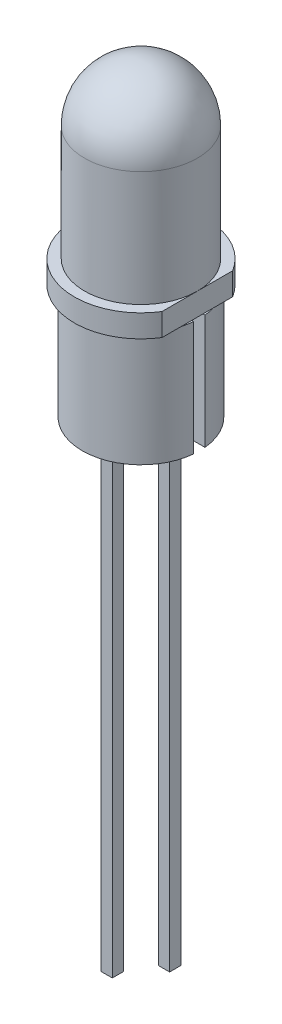
from build123d import *

# Parameters (mm, degrees)
EXTRUDE1_DEPTH     = 1
SKETCH3_W          = 0.5
SKETCH3_H          = 0.5
EXTRUDE2_DEPTH     = 27
SKETCH3_3_W        = 0.5
SKETCH3_3_H        = 0.5
EXTRUDE3_DEPTH     = 25.5
EXTRUDE5_DEPTH     = 5.08
CUT_EXTRUDE1_DEPTH = 0.01


with BuildPart() as part:
    # Sketch1 → Revolve1 (revolve)
    with BuildSketch(Plane.XY, mode=Mode.PRIVATE) as revolve1_sk:
        with BuildLine():
            ThreePointArc((0, 7.6), (1.767766953, 6.867766953), (2.5, 5.1))
            Line((2.5, 5.1), (2.5, 0))
            Line((2.5, 0), (0, 0))
            Line((0, 0), (0, 7.6))
        make_face()
    revolve(revolve1_sk.sketch.rotate(Axis((0, 0, 0), (0, 1, 0)), 180), axis=Axis((0, 0, 0), (0, 1, 0)))  # turned: the seam where the file's is

    # Sketch2 → Extrude1 (add)
    with BuildSketch(Plane.XZ.offset(1)):
        with BuildLine():
            ThreePointArc((2.5, 1.566045976), (-2.95, 0), (2.5, -1.566045976))
            Line((2.5, -1.566045976), (2.5, 1.566045976))
        make_face()
    extrude(amount=-EXTRUDE1_DEPTH)

    # Sketch3 → Extrude2 (add)
    with BuildSketch(Plane.XZ.offset(1)):
        with Locations((-1.27, 0)):
            Rectangle(SKETCH3_W, SKETCH3_H)
    extrude(amount=EXTRUDE2_DEPTH)

    # Sketch3_3 → Extrude3 (add)
    with BuildSketch(Plane.XZ.offset(1)):
        with Locations((1.27, 0)):
            Rectangle(SKETCH3_3_W, SKETCH3_3_H)
    extrude(amount=EXTRUDE3_DEPTH)

    # Sketch3_4 → Extrude5 (add)
    with BuildSketch(Plane.XZ.offset(1)):
        with BuildLine():
            Line((-2.587952859, 0.25), (-1.5325, 0.25))
            ThreePointArc((-1.5325, 0.25), (-0.9075, 0), (-1.5325, -0.25))
            Line((-1.5325, -0.25), (-2.587952859, -0.25))
            ThreePointArc((-2.587952859, -0.25), (0, -2.6), (2.587952859, -0.25))
            Line((2.587952859, -0.25), (1.5325, -0.25))
            ThreePointArc((1.5325, -0.25), (0.9075, 0), (1.5325, 0.25))
            Line((1.5325, 0.25), (2.587952859, 0.25))
            ThreePointArc((2.587952859, 0.25), (0, 2.6), (-2.587952859, 0.25))
        make_face()
    extrude(amount=EXTRUDE5_DEPTH)

    # Sketch4 → Cut-Extrude1 (cut)
    with BuildSketch(Plane.XZ.offset(6.08)):
        Polygon((-0.655355375, -1.39060173), (-0.685517559, -1.463426097), (-0.711012021, -1.461052679), (-0.721613287, -1.409114388), (-0.741332432, -1.458244135), (-0.767163129, -1.455850939), (-0.783243034, -1.37875442), (-0.758005692, -1.38108828), (-0.749975629, -1.433936382), (-0.729168667, -1.383778154), (-0.707887021, -1.385736224), (-0.697443983, -1.438821667), (-0.68003892, -1.388327205), align=None)
        Polygon((-0.521758682, -1.403069635), (-0.551920866, -1.475894002), (-0.577415328, -1.473520585), (-0.588016594, -1.421582294), (-0.607735739, -1.47071204), (-0.633566435, -1.468318844), (-0.649646341, -1.391222325), (-0.624408999, -1.393556186), (-0.616378935, -1.446404287), (-0.595571973, -1.396246059), (-0.574290328, -1.398204129), (-0.56384729, -1.451289572), (-0.546442227, -1.40079511), align=None)
        Polygon((-0.388161989, -1.415537541), (-0.418324173, -1.488361908), (-0.443818635, -1.48598849), (-0.454419901, -1.434050199), (-0.474139046, -1.483179946), (-0.499969742, -1.48078675), (-0.516049647, -1.403690231), (-0.490812306, -1.406024091), (-0.482782242, -1.458872193), (-0.46197528, -1.408713965), (-0.440693635, -1.410672034), (-0.430250597, -1.463757477), (-0.412845534, -1.413263015), align=None)
        Polygon((-0.355217986, -1.494283136), (-0.380178429, -1.491969054), (-0.377745676, -1.465742788), (-0.352785233, -1.46805687), align=None)
        with BuildLine():
            add(Edge.make_bspline(
                [(-0.248113536, -1.472723232), (-0.248253922, -1.473915629), (-0.248530252, -1.476262694), (-0.249473853, -1.479641652), (-0.250729627, -1.482831413), (-0.252387391, -1.485803259), (-0.254429344, -1.4885535), (-0.256837161, -1.491099172), (-0.259635793, -1.493419728), (-0.262773235, -1.495519624), (-0.266205588, -1.497388194), (-0.269935055, -1.498900162), (-0.273902913, -1.500135313), (-0.278129153, -1.501027047), (-0.282595924, -1.501653514), (-0.287317312, -1.501902071), (-0.292291902, -1.501898945), (-0.295681806, -1.5016359), (-0.297421289, -1.501500922)],
                knots=[0, 0, 0, 0, 0.90058851, 1.772681517, 2.626015198, 3.4705971, 4.32036009, 5.192579617, 6.09606324, 7.045094186, 8.024414859, 9.025845661, 10.062717298, 11.141783603, 12.26648138, 13.447065521, 14.689996688, 16, 16, 16, 16], degree=3))
            add(Edge.make_bspline(
                [(-0.297421289, -1.501500922), (-0.299408593, -1.501291869), (-0.303257868, -1.500886946), (-0.308800989, -1.499944314), (-0.313939341, -1.498819187), (-0.318688263, -1.497416894), (-0.323132496, -1.495802648), (-0.327380334, -1.494085584), (-0.331477438, -1.492249874), (-0.334109446, -1.490898096), (-0.335415751, -1.490227188)],
                knots=[0, 0, 0, 0, 1.201286002, 2.32681153, 3.378988205, 4.362447621, 5.301645787, 6.221100837, 7.117105525, 8, 8, 8, 8], degree=3))
            Line((-0.335415751, -1.490227188), (-0.33322034, -1.466394118))
            Line((-0.33322034, -1.466394118), (-0.330411796, -1.466651239))
            add(Edge.make_bspline(
                [(-0.330411796, -1.466651239), (-0.329166575, -1.467796655), (-0.326671467, -1.470091782), (-0.322547402, -1.473096042), (-0.318188353, -1.47580979), (-0.313584524, -1.478115397), (-0.308880084, -1.48003939), (-0.304179683, -1.481549193), (-0.299537996, -1.482653268), (-0.296437117, -1.483023451), (-0.294909422, -1.483205827)],
                knots=[0, 0, 0, 0, 1.017616757, 2.039048384, 3.065385926, 4.105318742, 5.134016281, 6.121643996, 7.074599551, 8, 8, 8, 8], degree=3))
            add(Edge.make_bspline(
                [(-0.294909422, -1.483205827), (-0.294487695, -1.483241941), (-0.293585992, -1.483319157), (-0.292134278, -1.483373746), (-0.290498946, -1.483382814), (-0.288731062, -1.483401798), (-0.286956546, -1.483315507), (-0.285283972, -1.483192549), (-0.283781583, -1.482962621), (-0.282849645, -1.482724809), (-0.282409422, -1.482612473)],
                knots=[0, 0, 0, 0, 0.808163916, 1.727951266, 2.772930738, 3.931137178, 5.10301526, 6.164173594, 7.132806016, 8, 8, 8, 8], degree=3))
            add(Edge.make_bspline(
                [(-0.282409422, -1.482612473), (-0.281918703, -1.482448763), (-0.280962984, -1.482129925), (-0.279617609, -1.481537584), (-0.278396185, -1.4808599), (-0.277289642, -1.48009404), (-0.276319294, -1.479155115), (-0.275599646, -1.477942168), (-0.275107425, -1.476500027), (-0.274967193, -1.475449948), (-0.2748936, -1.474898865)],
                knots=[0, 0, 0, 0, 1.070797189, 2.085469699, 3.038870334, 3.959349101, 4.866776555, 5.810352107, 6.850870467, 8, 8, 8, 8], degree=3))
            add(Edge.make_bspline(
                [(-0.2748936, -1.474898865), (-0.274871056, -1.474361982), (-0.274826642, -1.473304246), (-0.275272712, -1.471754544), (-0.276004603, -1.470276952), (-0.277160522, -1.468931276), (-0.278612196, -1.46765572), (-0.280421798, -1.46652515), (-0.282533606, -1.465458035), (-0.284096157, -1.464905717), (-0.284921289, -1.464614055)],
                knots=[0, 0, 0, 0, 0.825752642, 1.626850376, 2.461116157, 3.359088001, 4.348717287, 5.440157492, 6.648229248, 8, 8, 8, 8], degree=3))
            add(Edge.make_bspline(
                [(-0.284921289, -1.464614055), (-0.286796238, -1.463994137), (-0.290642297, -1.462722507), (-0.296536902, -1.461054323), (-0.302402704, -1.459265762), (-0.306141452, -1.457701982), (-0.30796322, -1.456940005)],
                knots=[0, 0, 0, 0, 0.974993485, 1.999993149, 3.025463197, 4, 4, 4, 4], degree=3))
            add(Edge.make_bspline(
                [(-0.30796322, -1.456940005), (-0.308943214, -1.456500785), (-0.310851641, -1.455645455), (-0.313566505, -1.454246027), (-0.316040774, -1.452761585), (-0.318292733, -1.451216392), (-0.320318879, -1.449592995), (-0.322120139, -1.447895058), (-0.323701826, -1.446130545), (-0.3250332, -1.44427218), (-0.326169708, -1.442338136), (-0.327123206, -1.440321228), (-0.327872522, -1.438211568), (-0.328450718, -1.436022174), (-0.328845015, -1.433738863), (-0.329055645, -1.431364867), (-0.32910794, -1.428904178), (-0.328975807, -1.427245359), (-0.328908631, -1.42640203)],
                knots=[0, 0, 0, 0, 1.283065564, 2.498625262, 3.646979989, 4.728630173, 5.759609417, 6.745952661, 7.683425923, 8.586370769, 9.472667486, 10.360712945, 11.247779533, 12.14392913, 13.063456901, 14.012738052, 14.989693508, 16, 16, 16, 16], degree=3))
            add(Edge.make_bspline(
                [(-0.328908631, -1.42640203), (-0.328764477, -1.425269782), (-0.328482025, -1.423051277), (-0.32759699, -1.419842499), (-0.32631903, -1.41684554), (-0.324690584, -1.414020102), (-0.322647072, -1.411425051), (-0.320254722, -1.409011987), (-0.317480907, -1.406811894), (-0.314359888, -1.40482933), (-0.310961723, -1.403086519), (-0.307337403, -1.401608337), (-0.303506133, -1.400454947), (-0.299489466, -1.399553272), (-0.295272931, -1.398998708), (-0.290866881, -1.398692798), (-0.28626042, -1.398721411), (-0.283133661, -1.39895106), (-0.281539169, -1.399068169)],
                knots=[0, 0, 0, 0, 0.898352996, 1.760216372, 2.612020855, 3.459189028, 4.321506127, 5.206609067, 6.130498421, 7.104463332, 8.114927556, 9.135353876, 10.183556409, 11.263499099, 12.374845914, 13.530505901, 14.740680187, 16, 16, 16, 16], degree=3))
            add(Edge.make_bspline(
                [(-0.281539169, -1.399068169), (-0.279908488, -1.399242299), (-0.27665549, -1.399589666), (-0.271824799, -1.400414813), (-0.267045258, -1.401461102), (-0.262365573, -1.402744441), (-0.257873382, -1.404167144), (-0.253661922, -1.40569312), (-0.249775116, -1.407292903), (-0.247348787, -1.408508103), (-0.246175245, -1.409095859)],
                knots=[0, 0, 0, 0, 1.064569354, 2.123677063, 3.179952291, 4.240175319, 5.273112175, 6.23860218, 7.148064866, 8, 8, 8, 8], degree=3))
            Line((-0.246175245, -1.409095859), (-0.248291543, -1.43199934))
            Line((-0.248291543, -1.43199934), (-0.251020973, -1.43174222))
            add(Edge.make_bspline(
                [(-0.251020973, -1.43174222), (-0.251995829, -1.430861762), (-0.253992805, -1.42905816), (-0.257324932, -1.426617934), (-0.261021517, -1.424361356), (-0.264998344, -1.422262437), (-0.269207224, -1.420456191), (-0.273552202, -1.419021056), (-0.277978999, -1.417968969), (-0.280987213, -1.417617692), (-0.282488536, -1.417442378)],
                knots=[0, 0, 0, 0, 0.896004807, 1.835450662, 2.81312924, 3.849541625, 4.901693663, 5.934613881, 6.969218071, 8, 8, 8, 8], degree=3))
            add(Edge.make_bspline(
                [(-0.282488536, -1.417442378), (-0.283556031, -1.41736002), (-0.285689074, -1.417195455), (-0.288890088, -1.417243675), (-0.292080537, -1.417532248), (-0.294137022, -1.418078648), (-0.295166543, -1.418352188)],
                knots=[0, 0, 0, 0, 1.004193435, 2.006555513, 3.00203922, 4, 4, 4, 4], degree=3))
            add(Edge.make_bspline(
                [(-0.295166543, -1.418352188), (-0.295606035, -1.418485758), (-0.296486336, -1.418753297), (-0.297719584, -1.419357624), (-0.298890862, -1.420071954), (-0.299939018, -1.420932432), (-0.300862918, -1.42189142), (-0.301570012, -1.422973779), (-0.302040535, -1.424167281), (-0.302164575, -1.425007113), (-0.30222746, -1.425432884)],
                knots=[0, 0, 0, 0, 1.035909408, 2.074917629, 3.091381753, 4.128574551, 5.129321193, 6.087511365, 7.030423625, 8, 8, 8, 8], degree=3))
            add(Edge.make_bspline(
                [(-0.30222746, -1.425432884), (-0.30225038, -1.426061006), (-0.302294131, -1.427260013), (-0.301882482, -1.429000848), (-0.301053004, -1.430536284), (-0.300016884, -1.431627475), (-0.298969504, -1.43238867), (-0.298024393, -1.4330126), (-0.29687876, -1.433591989), (-0.295582439, -1.434205533), (-0.294115905, -1.434815726), (-0.292483004, -1.435425001), (-0.290695609, -1.436064426), (-0.28943257, -1.436448346), (-0.288778093, -1.436647283)],
                knots=[0, 0, 0, 0, 1.176031048, 2.244899041, 3.313838711, 4.417270275, 5.036199696, 5.743514448, 6.540853141, 7.443472104, 8.4366176, 9.521775806, 10.715844498, 12, 12, 12, 12], degree=3))
            add(Edge.make_bspline(
                [(-0.288778093, -1.436647283), (-0.287024719, -1.437188984), (-0.283595768, -1.43824835), (-0.278436226, -1.439821907), (-0.273200308, -1.441592092), (-0.269710622, -1.443022235), (-0.267892017, -1.443767536)],
                knots=[0, 0, 0, 0, 0.997445159, 1.95063395, 2.931999127, 4, 4, 4, 4], degree=3))
            add(Edge.make_bspline(
                [(-0.267892017, -1.443767536), (-0.266996982, -1.444165802), (-0.265250305, -1.444943024), (-0.262779227, -1.44625508), (-0.260497186, -1.447624665), (-0.258391793, -1.449033604), (-0.256502434, -1.450552149), (-0.254800145, -1.452128806), (-0.253287942, -1.453773186), (-0.251973219, -1.455488674), (-0.250824963, -1.457277317), (-0.249899101, -1.45918817), (-0.249152808, -1.461198041), (-0.248539484, -1.463294498), (-0.248184389, -1.46551391), (-0.247963418, -1.467825748), (-0.247915361, -1.4702476), (-0.248046559, -1.471886548), (-0.248113536, -1.472723232)],
                knots=[0, 0, 0, 0, 1.235962929, 2.412004647, 3.527791942, 4.593898695, 5.606083112, 6.58329943, 7.519603077, 8.421527213, 9.307852042, 10.197139612, 11.094948425, 12.011489434, 12.948421262, 13.926133287, 14.941288146, 16, 16, 16, 16], degree=3))
        make_face()
        with BuildLine():
            Line((-0.160164983, -1.512456531), (-0.184195838, -1.510241341))
            Line((-0.184195838, -1.510241341), (-0.183424477, -1.501954158))
            add(Edge.make_bspline(
                [(-0.183424477, -1.501954158), (-0.184578993, -1.502656368), (-0.186809843, -1.504013234), (-0.190127683, -1.505812672), (-0.19327933, -1.507327346), (-0.196314753, -1.508577078), (-0.199396803, -1.509520262), (-0.202671593, -1.510002425), (-0.206170787, -1.510197349), (-0.208569943, -1.510030719), (-0.20980897, -1.509944664)],
                knots=[0, 0, 0, 0, 1.151271807, 2.224579471, 3.214562626, 4.129415358, 5.019918913, 5.952705277, 6.942688433, 8, 8, 8, 8], degree=3))
            add(Edge.make_bspline(
                [(-0.20980897, -1.509944664), (-0.210813447, -1.509828682), (-0.212768834, -1.509602904), (-0.21559046, -1.5090085), (-0.218206943, -1.50820224), (-0.220623003, -1.507183849), (-0.222853049, -1.505980581), (-0.224886297, -1.504554967), (-0.22669302, -1.502888377), (-0.22832631, -1.501050323), (-0.229738359, -1.499000357), (-0.230911904, -1.496747911), (-0.231831983, -1.494299802), (-0.232553108, -1.491673037), (-0.233013962, -1.488848714), (-0.233270067, -1.485833963), (-0.233291224, -1.482626036), (-0.233117966, -1.480434368), (-0.233028907, -1.479307797)],
                knots=[0, 0, 0, 0, 1.105679804, 2.15239592, 3.149250959, 4.096256038, 5.016039341, 5.916477075, 6.804759926, 7.698966383, 8.601193048, 9.52055213, 10.470189916, 11.456949629, 12.495584415, 13.595817429, 14.764191139, 16, 16, 16, 16], degree=3))
            Line((-0.233028907, -1.479307797), (-0.228519414, -1.430514284))
            Line((-0.228519414, -1.430514284), (-0.20435011, -1.432769031))
            Line((-0.20435011, -1.432769031), (-0.207791565, -1.469952575))
            add(Edge.make_bspline(
                [(-0.207791565, -1.469952575), (-0.207875574, -1.470862006), (-0.208035545, -1.472593778), (-0.208188447, -1.475080629), (-0.208296251, -1.477328913), (-0.208321728, -1.479360933), (-0.208257476, -1.481206454), (-0.208040583, -1.482887626), (-0.207701347, -1.484426243), (-0.207334997, -1.48536368), (-0.207158654, -1.485814917)],
                knots=[0, 0, 0, 0, 1.367849549, 2.604711154, 3.73150806, 4.738774859, 5.648104615, 6.494452549, 7.275302687, 8, 8, 8, 8], degree=3))
            add(Edge.make_bspline(
                [(-0.207158654, -1.485814917), (-0.206969063, -1.486232052), (-0.206599495, -1.487045168), (-0.205790976, -1.488123345), (-0.20482863, -1.489054973), (-0.20365081, -1.489825537), (-0.202261679, -1.490468148), (-0.200602754, -1.490935367), (-0.19869457, -1.491341432), (-0.197324193, -1.491491053), (-0.196596945, -1.491570455)],
                knots=[0, 0, 0, 0, 0.862146275, 1.680569997, 2.525040964, 3.377080088, 4.323068773, 5.401195608, 6.620835126, 8, 8, 8, 8], degree=3))
            add(Edge.make_bspline(
                [(-0.196596945, -1.491570455), (-0.196069756, -1.491606169), (-0.194982779, -1.491679806), (-0.193301686, -1.491609608), (-0.191526916, -1.491400102), (-0.189013526, -1.490985952), (-0.185814683, -1.490104715), (-0.183397248, -1.488975316), (-0.182178433, -1.488405898)],
                knots=[0, 0, 0, 0, 0.636343377, 1.312035106, 2.023532984, 2.788877082, 4.381024352, 6, 6, 6, 6], degree=3))
            Line((-0.182178433, -1.488405898), (-0.177253591, -1.435280898))
            Line((-0.177253591, -1.435280898), (-0.153222736, -1.437496088))
            Line((-0.153222736, -1.437496088), (-0.160164983, -1.512456531))
        make_face()
        with BuildLine():
            Line((-0.062505196, -1.521572741), (-0.0866745, -1.519337773))
            Line((-0.0866745, -1.519337773), (-0.083233044, -1.482154229))
            add(Edge.make_bspline(
                [(-0.083233044, -1.482154229), (-0.083120754, -1.480645307), (-0.082895909, -1.477623887), (-0.082817229, -1.473879451), (-0.082914609, -1.471028842), (-0.083069528, -1.469173946), (-0.083375097, -1.467605831), (-0.083698137, -1.466691239), (-0.083846177, -1.466272108)],
                knots=[0, 0, 0, 0, 1.702009942, 3.408054733, 4.209582085, 4.909917854, 5.500447295, 6, 6, 6, 6], degree=3))
            add(Edge.make_bspline(
                [(-0.083846177, -1.466272108), (-0.084042538, -1.465854922), (-0.084429718, -1.465032327), (-0.08526265, -1.463950395), (-0.086262932, -1.463032258), (-0.087448278, -1.462264163), (-0.088840032, -1.461627323), (-0.090482416, -1.461121054), (-0.092390297, -1.460728829), (-0.093760071, -1.460577239), (-0.094487, -1.460496792)],
                knots=[0, 0, 0, 0, 0.864192863, 1.703986622, 2.54551408, 3.404364673, 4.34644313, 5.411937724, 6.626535882, 8, 8, 8, 8], degree=3))
            add(Edge.make_bspline(
                [(-0.094487, -1.460496792), (-0.095595804, -1.460447064), (-0.097858192, -1.4603456), (-0.100714428, -1.460796709), (-0.103052256, -1.461401308), (-0.104922302, -1.461989303), (-0.106859463, -1.462777028), (-0.108169277, -1.463373089), (-0.108846177, -1.463681127)],
                knots=[0, 0, 0, 0, 1.339357892, 2.732805435, 3.473325484, 4.259912674, 5.100739573, 6, 6, 6, 6], degree=3))
            Line((-0.108846177, -1.463681127), (-0.113771019, -1.516825906))
            Line((-0.113771019, -1.516825906), (-0.137801873, -1.514590938))
            Line((-0.137801873, -1.514590938), (-0.130859626, -1.439630495))
            Line((-0.130859626, -1.439630495), (-0.106828772, -1.441865463))
            Line((-0.106828772, -1.441865463), (-0.107580354, -1.450132868))
            add(Edge.make_bspline(
                [(-0.107580354, -1.450132868), (-0.106460188, -1.449435079), (-0.104278258, -1.448075881), (-0.100977579, -1.446295664), (-0.097760054, -1.444805586), (-0.094609608, -1.443563894), (-0.091414897, -1.442652186), (-0.088120084, -1.44209451), (-0.084688801, -1.441917117), (-0.08237541, -1.442066298), (-0.08119586, -1.442142362)],
                knots=[0, 0, 0, 0, 1.125391853, 2.192109419, 3.195913079, 4.148252987, 5.077419607, 6.024015203, 6.992486454, 8, 8, 8, 8], degree=3))
            add(Edge.make_bspline(
                [(-0.08119586, -1.442142362), (-0.080210957, -1.44225009), (-0.078293646, -1.442459804), (-0.075525409, -1.443059579), (-0.072950877, -1.443878762), (-0.070539009, -1.444853124), (-0.068325902, -1.446073096), (-0.066300573, -1.44749759), (-0.064471176, -1.449137608), (-0.062809825, -1.450957518), (-0.061396173, -1.453009462), (-0.060162037, -1.455236609), (-0.059234532, -1.457688782), (-0.058489349, -1.460319867), (-0.058004033, -1.463157538), (-0.057762574, -1.466194077), (-0.057706314, -1.46942779), (-0.057884231, -1.471639426), (-0.057975924, -1.472779229)],
                knots=[0, 0, 0, 0, 1.084667264, 2.111522093, 3.095855619, 4.041277855, 4.955890058, 5.857467287, 6.747401758, 7.642157225, 8.549643474, 9.470590754, 10.424031703, 11.413964681, 12.462254151, 13.571074575, 14.748214336, 16, 16, 16, 16], degree=3))
            Line((-0.057975924, -1.472779229), (-0.062505196, -1.521572741))
        make_face()
        Polygon((0.032266933, -1.530412053), (-0.03943006, -1.523766483), (-0.030213288, -1.424379616), (-0.004580377, -1.426772812), (-0.012017086, -1.506934996), (0.034046997, -1.511187369), align=None)
        Polygon((0.119428603, -1.538547732), (0.047533825, -1.531882384), (0.056750597, -1.432495517), (0.128645375, -1.439160865), (0.126865312, -1.458385548), (0.080484774, -1.454093618), (0.078882717, -1.471241561), (0.121920692, -1.475236814), (0.120140629, -1.494461498), (0.077102654, -1.490466245), (0.074828129, -1.515031118), (0.121208667, -1.519323048), align=None)
        with BuildLine():
            add(Edge.make_bspline(
                [(0.239316055, -1.499704273), (0.239193333, -1.500847086), (0.238950999, -1.503103745), (0.238317972, -1.506415515), (0.23754193, -1.509624942), (0.236539274, -1.512717949), (0.235382153, -1.515711806), (0.234007248, -1.518590636), (0.232446193, -1.521358648), (0.230704395, -1.524000612), (0.22883587, -1.526504528), (0.226849369, -1.528838701), (0.22479067, -1.531025465), (0.222636341, -1.533047092), (0.220380144, -1.534887639), (0.218034722, -1.536547972), (0.215624368, -1.538073617), (0.213934362, -1.538931436), (0.213089789, -1.539360128)],
                knots=[0, 0, 0, 0, 1.110090179, 2.192044121, 3.254966808, 4.298472341, 5.331150686, 6.354038145, 7.378015901, 8.399196196, 9.4094707, 10.394735033, 11.359019723, 12.309935786, 13.247097763, 14.169751205, 15.085341168, 16, 16, 16, 16], degree=3))
            add(Edge.make_bspline(
                [(0.213089789, -1.539360128), (0.211793815, -1.539943913), (0.209198802, -1.541112867), (0.205117352, -1.542450475), (0.200895563, -1.543444093), (0.196486056, -1.544068929), (0.191826954, -1.544395454), (0.18683636, -1.544457238), (0.18146364, -1.544307248), (0.177764366, -1.544005993), (0.175846909, -1.543849843)],
                knots=[0, 0, 0, 0, 0.897299183, 1.796721742, 2.707829584, 3.633617596, 4.606479989, 5.656017227, 6.785035701, 8, 8, 8, 8], degree=3))
            Line((0.175846909, -1.543849843), (0.140799441, -1.540586393))
            Line((0.140799441, -1.540586393), (0.150016213, -1.441199526))
            Line((0.150016213, -1.441199526), (0.186072384, -1.44454209))
            add(Edge.make_bspline(
                [(0.186072384, -1.44454209), (0.188026523, -1.444745793), (0.191801819, -1.445139336), (0.197219291, -1.446039811), (0.202207891, -1.44710329), (0.206756896, -1.448435542), (0.210901334, -1.449962588), (0.214680973, -1.451634539), (0.218090121, -1.453497827), (0.220130433, -1.454952281), (0.221119852, -1.455657596)],
                knots=[0, 0, 0, 0, 1.266615117, 2.447035418, 3.539391318, 4.553716614, 5.500588623, 6.385451449, 7.217048994, 8, 8, 8, 8], degree=3))
            add(Edge.make_bspline(
                [(0.221119852, -1.455657596), (0.221911963, -1.456274646), (0.223481268, -1.457497127), (0.225697193, -1.459490569), (0.227739338, -1.461623492), (0.229656517, -1.463869671), (0.231405702, -1.466240552), (0.233032474, -1.46872541), (0.234453706, -1.471359314), (0.235777859, -1.474086454), (0.236894548, -1.476939742), (0.237859501, -1.479885809), (0.238577249, -1.482952754), (0.239143134, -1.486106701), (0.239464847, -1.48937353), (0.239626591, -1.492726959), (0.239591135, -1.496188347), (0.239408843, -1.498518299), (0.239316055, -1.499704273)],
                knots=[0, 0, 0, 0, 0.965020829, 1.911869547, 2.862084641, 3.801779837, 4.748628555, 5.692609604, 6.654127927, 7.623591957, 8.605099481, 9.597189602, 10.600951773, 11.630375302, 12.675308291, 13.753889975, 14.856702544, 16, 16, 16, 16], degree=3))
        make_face()
        with BuildLine():
            add(Edge.make_bspline(
                [(0.212832669, -1.497034178), (0.212939465, -1.49545262), (0.213146001, -1.492394008), (0.212886564, -1.487925231), (0.21214949, -1.483769274), (0.211107618, -1.48054271), (0.210054719, -1.478130394), (0.209091946, -1.476436629), (0.20802813, -1.474795745), (0.206797061, -1.47326466), (0.205443613, -1.471801095), (0.203932626, -1.47044297), (0.202290797, -1.469148371), (0.201110116, -1.468373167), (0.200510675, -1.46797959)],
                knots=[0, 0, 0, 0, 1.705749779, 3.298789384, 4.806982686, 6.23946175, 6.938714637, 7.637967523, 8.335054416, 9.042477594, 9.750790903, 10.479588431, 11.228074284, 12, 12, 12, 12], degree=3))
            add(Edge.make_bspline(
                [(0.200510675, -1.46797959), (0.199883672, -1.46760603), (0.19864828, -1.466870002), (0.19670191, -1.465961952), (0.194735437, -1.465187551), (0.192644623, -1.464553153), (0.190281994, -1.463998987), (0.187462917, -1.463553966), (0.184122333, -1.463086008), (0.181709173, -1.462859629), (0.180415738, -1.462738292)],
                knots=[0, 0, 0, 0, 0.834463409, 1.644154416, 2.453704901, 3.250542573, 4.141482061, 5.22766562, 6.514049856, 8, 8, 8, 8], degree=3))
            Line((0.180415738, -1.462738292), (0.173928396, -1.462144938))
            Line((0.173928396, -1.462144938), (0.16815308, -1.52434826))
            Line((0.16815308, -1.52434826), (0.174640422, -1.524941615))
            add(Edge.make_bspline(
                [(0.174640422, -1.524941615), (0.175378473, -1.525011901), (0.176800687, -1.525147342), (0.178859793, -1.525272806), (0.180770764, -1.525399033), (0.182531241, -1.525487382), (0.184147163, -1.525492184), (0.185605096, -1.525512658), (0.186916917, -1.52543949), (0.188471459, -1.525346851), (0.190317812, -1.525095837), (0.192475067, -1.524575671), (0.194645739, -1.523970569), (0.196045787, -1.523393577), (0.196752764, -1.523102216)],
                knots=[0, 0, 0, 0, 1.188333874, 2.289901336, 3.306416931, 4.258483362, 5.114563353, 5.896601528, 6.594815215, 7.219763455, 8.393011118, 9.574842304, 10.775378443, 12, 12, 12, 12], degree=3))
            add(Edge.make_bspline(
                [(0.196752764, -1.523102216), (0.197934301, -1.522511428), (0.200243017, -1.521357033), (0.203299463, -1.519047003), (0.20594896, -1.516408026), (0.208131141, -1.513336208), (0.20990216, -1.509867893), (0.211268565, -1.505972432), (0.212316858, -1.501660297), (0.212656347, -1.498615543), (0.212832669, -1.497034178)],
                knots=[0, 0, 0, 0, 0.980860401, 1.916594154, 2.83557349, 3.752876285, 4.707000063, 5.723077786, 6.817426984, 8, 8, 8, 8], degree=3))
        make_face(mode=Mode.SUBTRACT)
        Polygon((0.278736133, -1.553446876), (0.25377569, -1.551132794), (0.256208443, -1.524906528), (0.281168886, -1.52722061), align=None)
        with BuildLine():
            add(Edge.make_bspline(
                [(0.340923653, -1.561258017), (0.339324981, -1.561082609), (0.336191108, -1.560738759), (0.33164068, -1.559854466), (0.327321112, -1.55873302), (0.323250487, -1.557335043), (0.319421653, -1.555664027), (0.315909487, -1.553648539), (0.312629603, -1.551411339), (0.310708603, -1.54963959), (0.309752766, -1.548758017)],
                knots=[0, 0, 0, 0, 1.127116313, 2.209483354, 3.246509375, 4.25363422, 5.224159382, 6.170115381, 7.089500056, 8, 8, 8, 8], degree=3))
            add(Edge.make_bspline(
                [(0.309752766, -1.548758017), (0.308877819, -1.54782241), (0.307128667, -1.545951992), (0.304936008, -1.542767138), (0.303087493, -1.539324433), (0.301587303, -1.535604188), (0.300522841, -1.531585661), (0.299901256, -1.527280521), (0.299696611, -1.522700367), (0.299911404, -1.519570763), (0.300021754, -1.517962922)],
                knots=[0, 0, 0, 0, 0.919337953, 1.83789453, 2.768295796, 3.722697843, 4.713165993, 5.747518477, 6.842782892, 8, 8, 8, 8], degree=3))
            add(Edge.make_bspline(
                [(0.300021754, -1.517962922), (0.30022019, -1.516276653), (0.300604697, -1.513009201), (0.301693971, -1.508337537), (0.303197985, -1.504070815), (0.305101481, -1.500196009), (0.307407516, -1.496727824), (0.309968424, -1.493568916), (0.312904497, -1.490812971), (0.315074466, -1.489267047), (0.316160994, -1.488492985)],
                knots=[0, 0, 0, 0, 1.169874094, 2.266842571, 3.299017176, 4.28282495, 5.234592693, 6.164557564, 7.080973184, 8, 8, 8, 8], degree=3))
            add(Edge.make_bspline(
                [(0.316160994, -1.488492985), (0.317269897, -1.487831633), (0.3194971, -1.486503325), (0.32307344, -1.484898522), (0.326866415, -1.483678824), (0.3308259, -1.482776281), (0.33491595, -1.48219863), (0.339071168, -1.481876407), (0.343282397, -1.481851364), (0.346093291, -1.482059153), (0.347509887, -1.482163871)],
                knots=[0, 0, 0, 0, 0.951091244, 1.910241889, 2.881417019, 3.883383244, 4.899762613, 5.923168624, 6.953347091, 8, 8, 8, 8], degree=3))
            add(Edge.make_bspline(
                [(0.347509887, -1.482163871), (0.348764869, -1.48229903), (0.351226288, -1.482564119), (0.354808868, -1.483234073), (0.358233251, -1.484045858), (0.361475678, -1.485116904), (0.364587995, -1.486305385), (0.367573858, -1.487606985), (0.370438713, -1.489034226), (0.372270872, -1.490086023), (0.373182355, -1.490609283)],
                knots=[0, 0, 0, 0, 1.111075928, 2.179172556, 3.207037671, 4.207604234, 5.183341174, 6.140033088, 7.074682433, 8, 8, 8, 8], degree=3))
            Line((0.373182355, -1.490609283), (0.371283621, -1.511099789))
            Line((0.371283621, -1.511099789), (0.367881722, -1.510783333))
            add(Edge.make_bspline(
                [(0.367881722, -1.510783333), (0.36740906, -1.510293432), (0.366386053, -1.509233113), (0.364691062, -1.507569808), (0.362660527, -1.505753926), (0.361072256, -1.50466019), (0.36022745, -1.504078428)],
                knots=[0, 0, 0, 0, 0.800878954, 1.733386287, 2.794381847, 4, 4, 4, 4], degree=3))
            add(Edge.make_bspline(
                [(0.36022745, -1.504078428), (0.359329898, -1.503515519), (0.357488794, -1.502360852), (0.354954313, -1.501251972), (0.35276522, -1.500483903), (0.350952102, -1.500015053), (0.348998019, -1.499632805), (0.347636635, -1.499486149), (0.346936311, -1.499410707)],
                knots=[0, 0, 0, 0, 1.3379742, 2.744522015, 3.485215376, 4.269639074, 5.109866742, 6, 6, 6, 6], degree=3))
            add(Edge.make_bspline(
                [(0.346936311, -1.499410707), (0.346158889, -1.499357872), (0.344637481, -1.499254474), (0.34240273, -1.499326394), (0.340294084, -1.499636819), (0.338291548, -1.500088619), (0.336432962, -1.500823505), (0.334667695, -1.50170632), (0.333041948, -1.502829143), (0.331535664, -1.504135724), (0.33017643, -1.505620884), (0.328952537, -1.507261845), (0.327898185, -1.50905761), (0.326969447, -1.510997942), (0.326233297, -1.51309891), (0.32561914, -1.515345703), (0.32513556, -1.517743565), (0.324955772, -1.519404844), (0.324863526, -1.520257226)],
                knots=[0, 0, 0, 0, 1.085847928, 2.124994152, 3.108863779, 4.053983921, 4.979052411, 5.887398504, 6.799965494, 7.725033985, 8.661626012, 9.600874533, 10.573346603, 11.559959446, 12.594829749, 13.671695504, 14.805376373, 16, 16, 16, 16], degree=3))
            add(Edge.make_bspline(
                [(0.324863526, -1.520257226), (0.324797994, -1.521133583), (0.324670491, -1.522838703), (0.324696335, -1.5253308), (0.32487549, -1.52767611), (0.325289773, -1.52986777), (0.32581939, -1.531932582), (0.326585346, -1.53383399), (0.327492741, -1.535603591), (0.32860863, -1.537201588), (0.329880246, -1.538663877), (0.331327644, -1.539945887), (0.332928329, -1.541064849), (0.334680825, -1.542016873), (0.33658553, -1.542804311), (0.338643961, -1.543439592), (0.340853815, -1.543919175), (0.342391734, -1.544084727), (0.343178399, -1.544169409)],
                knots=[0, 0, 0, 0, 1.227137007, 2.387626998, 3.478296397, 4.507999883, 5.499941637, 6.450843677, 7.365368786, 8.272303185, 9.166427399, 10.066649758, 10.966023695, 11.889226233, 12.847060822, 13.840412525, 14.895343621, 16, 16, 16, 16], degree=3))
            add(Edge.make_bspline(
                [(0.343178399, -1.544169409), (0.343916354, -1.544222856), (0.345357976, -1.544327265), (0.347479357, -1.544357871), (0.349501811, -1.544214818), (0.351419751, -1.543945223), (0.353200118, -1.543533555), (0.354853215, -1.543117693), (0.356340826, -1.542596098), (0.357269148, -1.542202728), (0.357715583, -1.542013555)],
                knots=[0, 0, 0, 0, 1.19472897, 2.333948801, 3.422440868, 4.465847223, 5.457796971, 6.371966855, 7.217069639, 8, 8, 8, 8], degree=3))
            add(Edge.make_bspline(
                [(0.357715583, -1.542013555), (0.35848133, -1.541638502), (0.359952312, -1.540918035), (0.361967515, -1.539647434), (0.363761429, -1.538328254), (0.364897196, -1.537440758), (0.365448969, -1.537009599)],
                knots=[0, 0, 0, 0, 1.107280127, 2.127059427, 3.090097063, 4, 4, 4, 4], degree=3))
            Line((0.365448969, -1.537009599), (0.368850868, -1.537326055))
            Line((0.368850868, -1.537326055), (0.366952134, -1.55783634))
            add(Edge.make_bspline(
                [(0.366952134, -1.55783634), (0.365959652, -1.558175535), (0.363975533, -1.558853639), (0.360937744, -1.559700916), (0.357848975, -1.560412488), (0.354697329, -1.560994845), (0.351442861, -1.561402109), (0.348059235, -1.561570816), (0.344532077, -1.561532039), (0.34214263, -1.561350586), (0.340923653, -1.561258017)],
                knots=[0, 0, 0, 0, 0.950641764, 1.900475359, 2.857315296, 3.823257762, 4.804735534, 5.828134187, 6.892021088, 8, 8, 8, 8], degree=3))
        make_face()
        with BuildLine():
            add(Edge.make_bspline(
                [(0.462804161, -1.53282853), (0.462641454, -1.53432956), (0.462324509, -1.537253489), (0.46138392, -1.541468192), (0.460200741, -1.545416863), (0.458663048, -1.549085689), (0.456824263, -1.552485433), (0.454656446, -1.555610879), (0.45216865, -1.558456894), (0.449375428, -1.561010209), (0.446306944, -1.563250678), (0.442981313, -1.56513756), (0.439422432, -1.566673429), (0.435608585, -1.567809192), (0.431565175, -1.568630933), (0.427272469, -1.569037301), (0.422747921, -1.56916011), (0.419666404, -1.568925821), (0.418085016, -1.568805587)],
                knots=[0, 0, 0, 0, 1.112153489, 2.166417553, 3.177945045, 4.147300644, 5.093288899, 6.022144657, 6.945184808, 7.873938852, 8.806144959, 9.739869978, 10.686856374, 11.656942643, 12.66817823, 13.723338015, 14.831651695, 16, 16, 16, 16], degree=3))
            add(Edge.make_bspline(
                [(0.418085016, -1.568805587), (0.416505491, -1.568626298), (0.413433656, -1.56827762), (0.409004884, -1.567351362), (0.404861691, -1.566167682), (0.401040728, -1.56460413), (0.397482651, -1.562802892), (0.394267682, -1.560621237), (0.391338644, -1.558166364), (0.388739254, -1.55539806), (0.386465834, -1.552382767), (0.384557867, -1.549124183), (0.382978773, -1.545671283), (0.38179709, -1.541984171), (0.380967967, -1.538087829), (0.380496597, -1.533982512), (0.380402056, -1.52966644), (0.380601463, -1.526735901), (0.380703687, -1.525233594)],
                knots=[0, 0, 0, 0, 1.171005177, 2.27735246, 3.330568948, 4.34202592, 5.315602217, 6.26433293, 7.198771692, 8.126834468, 9.056828592, 9.975983149, 10.904490999, 11.849481629, 12.823445843, 13.835975955, 14.890637285, 16, 16, 16, 16], degree=3))
            add(Edge.make_bspline(
                [(0.380703687, -1.525233594), (0.380876652, -1.523726686), (0.381214986, -1.520779051), (0.382127004, -1.516528458), (0.383357134, -1.512555778), (0.38489668, -1.508870792), (0.386747064, -1.50544979), (0.388920148, -1.502322303), (0.391425987, -1.499480062), (0.394223767, -1.496937083), (0.397309717, -1.494710367), (0.400635599, -1.4928233), (0.404212959, -1.491321566), (0.408004723, -1.490142577), (0.412044806, -1.489361102), (0.416313843, -1.488943045), (0.420819446, -1.488823635), (0.423887653, -1.489057429), (0.425462389, -1.489177423)],
                knots=[0, 0, 0, 0, 1.116251249, 2.183480266, 3.195222106, 4.174239216, 5.119087573, 6.053580359, 6.97185923, 7.903081215, 8.831312821, 9.768134902, 10.712072634, 11.682411479, 12.686720471, 13.735779907, 14.837905261, 16, 16, 16, 16], degree=3))
            add(Edge.make_bspline(
                [(0.425462389, -1.489177423), (0.427048075, -1.489358149), (0.430138589, -1.489710386), (0.43460081, -1.490619541), (0.438748185, -1.491847811), (0.442600016, -1.493356167), (0.446108531, -1.495239466), (0.449345646, -1.497368911), (0.452253479, -1.499846636), (0.454843786, -1.502616456), (0.457104853, -1.505649442), (0.459007438, -1.508909662), (0.460570276, -1.512372072), (0.461723486, -1.516061851), (0.462569831, -1.519952562), (0.462996127, -1.524068377), (0.463139951, -1.528389138), (0.462917797, -1.531326173), (0.462804161, -1.53282853)],
                knots=[0, 0, 0, 0, 1.174474058, 2.289059499, 3.347095022, 4.355582354, 5.328246868, 6.273187714, 7.202849284, 8.133384566, 9.059403153, 9.981687753, 10.90713384, 11.849553675, 12.822399797, 13.833220082, 14.89164513, 16, 16, 16, 16], degree=3))
        make_face()
        with BuildLine():
            add(Edge.make_bspline(
                [(0.431554161, -1.548315081), (0.431981887, -1.547857152), (0.432843372, -1.546934835), (0.43392873, -1.545337773), (0.434893123, -1.543602986), (0.435752871, -1.541669727), (0.436462639, -1.539447726), (0.437069125, -1.536869273), (0.437552742, -1.53389391), (0.437781771, -1.531774977), (0.437903054, -1.530652897)],
                knots=[0, 0, 0, 0, 0.784146223, 1.579354345, 2.411425917, 3.269500931, 4.225642563, 5.329689518, 6.585937942, 8, 8, 8, 8], degree=3))
            add(Edge.make_bspline(
                [(0.437903054, -1.530652897), (0.437988649, -1.529592068), (0.438152752, -1.527558246), (0.438181396, -1.524626342), (0.438091803, -1.521947031), (0.437759642, -1.519517109), (0.437318187, -1.517318426), (0.436724792, -1.515335039), (0.435984637, -1.513567065), (0.435356739, -1.512509896), (0.435054952, -1.51200179)],
                knots=[0, 0, 0, 0, 1.329974025, 2.54982663, 3.663526759, 4.677599082, 5.611837141, 6.464383833, 7.261937439, 8, 8, 8, 8], degree=3))
            add(Edge.make_bspline(
                [(0.435054952, -1.51200179), (0.434729915, -1.511538107), (0.434091368, -1.510627189), (0.432953066, -1.509427965), (0.431679331, -1.508428167), (0.430271167, -1.507645247), (0.428796568, -1.506987444), (0.427232705, -1.506503185), (0.425610484, -1.506106905), (0.424488805, -1.505989412), (0.423919668, -1.505929796)],
                knots=[0, 0, 0, 0, 1.032019946, 2.027433999, 3.004289909, 3.974011048, 4.95956602, 5.944753945, 6.957172537, 8, 8, 8, 8], degree=3))
            add(Edge.make_bspline(
                [(0.423919668, -1.505929796), (0.423353083, -1.505889009), (0.422253714, -1.505809868), (0.420638595, -1.505823354), (0.419111537, -1.505988637), (0.417646325, -1.506251935), (0.416222763, -1.506716966), (0.414824416, -1.507423467), (0.413442976, -1.508378648), (0.412578481, -1.509150401), (0.412131693, -1.509549258)],
                knots=[0, 0, 0, 0, 1.065985282, 2.068378468, 3.026326902, 3.946111502, 4.857870197, 5.826310911, 6.876595141, 8, 8, 8, 8], degree=3))
            add(Edge.make_bspline(
                [(0.412131693, -1.509549258), (0.41173093, -1.509981468), (0.410894354, -1.510883688), (0.409826617, -1.512489642), (0.408803403, -1.514320232), (0.407906069, -1.516423601), (0.407102859, -1.518800295), (0.406473996, -1.52147867), (0.40592318, -1.524453034), (0.405714123, -1.526549955), (0.405604794, -1.527646568)],
                knots=[0, 0, 0, 0, 0.720604642, 1.504230168, 2.353300379, 3.285998403, 4.299349121, 5.421119604, 6.651340648, 8, 8, 8, 8], degree=3))
            add(Edge.make_bspline(
                [(0.405604794, -1.527646568), (0.405530465, -1.528641552), (0.405387357, -1.530557232), (0.405315138, -1.533350312), (0.405433234, -1.535947141), (0.40570353, -1.538354252), (0.406133833, -1.540559412), (0.406720776, -1.542562645), (0.407466063, -1.544365117), (0.40810421, -1.545440506), (0.408413338, -1.545961442)],
                knots=[0, 0, 0, 0, 1.269942145, 2.445068147, 3.553933547, 4.576119153, 5.525731831, 6.40990588, 7.229732334, 8, 8, 8, 8], degree=3))
            add(Edge.make_bspline(
                [(0.408413338, -1.545961442), (0.408738919, -1.546405359), (0.409381927, -1.547282079), (0.410524428, -1.548433778), (0.411778276, -1.549430822), (0.413157764, -1.550274414), (0.414668092, -1.550932824), (0.416285416, -1.55148251), (0.418027819, -1.551843855), (0.419231021, -1.551995548), (0.419845301, -1.552072992)],
                knots=[0, 0, 0, 0, 0.983434844, 1.942247707, 2.890563898, 3.842975875, 4.824642141, 5.831338168, 6.892816417, 8, 8, 8, 8], degree=3))
            add(Edge.make_bspline(
                [(0.419845301, -1.552072992), (0.420921398, -1.552118935), (0.423049176, -1.552209779), (0.425685749, -1.551746688), (0.427684629, -1.551088678), (0.429087091, -1.550352575), (0.430407687, -1.549453577), (0.431169465, -1.5486971), (0.431554161, -1.548315081)],
                knots=[0, 0, 0, 0, 1.518971802, 3.003480105, 3.751996149, 4.485512229, 5.235187506, 6, 6, 6, 6], degree=3))
        make_face(mode=Mode.SUBTRACT)
        with BuildLine():
            Line((0.5542106, -1.525531749), (0.549285758, -1.578676527))
            Line((0.549285758, -1.578676527), (0.525116454, -1.57642178))
            Line((0.525116454, -1.57642178), (0.528577689, -1.538981116))
            add(Edge.make_bspline(
                [(0.528577689, -1.538981116), (0.528660131, -1.538104548), (0.528819328, -1.536411893), (0.528994337, -1.533978547), (0.529118277, -1.53174316), (0.529178601, -1.529712504), (0.529184203, -1.527854717), (0.529014182, -1.526170699), (0.528771693, -1.524633683), (0.52843955, -1.523701955), (0.528281011, -1.523257223)],
                knots=[0, 0, 0, 0, 1.333428439, 2.574852367, 3.694800292, 4.7237138, 5.652392666, 6.504886966, 7.286353808, 8, 8, 8, 8], degree=3))
            add(Edge.make_bspline(
                [(0.528281011, -1.523257223), (0.52810271, -1.522861202), (0.52775132, -1.522080737), (0.527000602, -1.521035477), (0.526082406, -1.520130929), (0.524956032, -1.519388545), (0.523629412, -1.518773007), (0.522057849, -1.518288761), (0.520240201, -1.517887107), (0.518927922, -1.517751465), (0.518233543, -1.517679692)],
                knots=[0, 0, 0, 0, 0.855211979, 1.685423201, 2.522536054, 3.384842079, 4.333401899, 5.398918671, 6.623665343, 8, 8, 8, 8], degree=3))
            add(Edge.make_bspline(
                [(0.518233543, -1.517679692), (0.517646956, -1.517649571), (0.516473189, -1.517589299), (0.514708256, -1.517685303), (0.512952456, -1.517987863), (0.510683258, -1.518634097), (0.507985105, -1.519580936), (0.505931974, -1.520513461), (0.504942404, -1.520962919)],
                knots=[0, 0, 0, 0, 0.762654388, 1.526077775, 2.290605242, 3.071788349, 4.588658617, 6, 6, 6, 6], degree=3))
            Line((0.504942404, -1.520962919), (0.500017562, -1.574107698))
            Line((0.500017562, -1.574107698), (0.475986708, -1.57187273))
            Line((0.475986708, -1.57187273), (0.482928954, -1.496912287))
            Line((0.482928954, -1.496912287), (0.506959809, -1.499147255))
            Line((0.506959809, -1.499147255), (0.506208227, -1.50741466))
            add(Edge.make_bspline(
                [(0.506208227, -1.50741466), (0.507296562, -1.50673218), (0.509412505, -1.5054053), (0.512595696, -1.503637509), (0.515699913, -1.502155394), (0.51872026, -1.500867373), (0.521788168, -1.499910817), (0.524955405, -1.499344354), (0.528240791, -1.49911211), (0.530456927, -1.499253402), (0.531584018, -1.499325261)],
                knots=[0, 0, 0, 0, 1.133892702, 2.204516442, 3.211881797, 4.16946617, 5.100963188, 6.041578558, 7.003978887, 8, 8, 8, 8], degree=3))
            add(Edge.make_bspline(
                [(0.531584018, -1.499325261), (0.532783665, -1.499469778), (0.53512868, -1.499752273), (0.538473562, -1.500733226), (0.541575527, -1.502053813), (0.544401131, -1.503786038), (0.546925215, -1.505886779), (0.549118353, -1.508362042), (0.550951345, -1.511209219), (0.551865684, -1.513307414), (0.552331644, -1.514376685)],
                knots=[0, 0, 0, 0, 1.068914945, 2.089466037, 3.075778789, 4.048490179, 5.014726373, 5.974674725, 6.967864302, 8, 8, 8, 8], degree=3))
            add(Edge.make_bspline(
                [(0.552331644, -1.514376685), (0.55360972, -1.513521226), (0.556103771, -1.511851875), (0.559867612, -1.509609497), (0.563570884, -1.507729612), (0.567158744, -1.506126002), (0.570689327, -1.504887389), (0.574167551, -1.50412382), (0.577574856, -1.503716143), (0.579810021, -1.503848595), (0.580911549, -1.503913869)],
                knots=[0, 0, 0, 0, 1.18908878, 2.320399823, 3.385098509, 4.398564908, 5.35776941, 6.271761379, 7.14829353, 8, 8, 8, 8], degree=3))
            add(Edge.make_bspline(
                [(0.580911549, -1.503913869), (0.581889868, -1.504021621), (0.583794111, -1.504231355), (0.586536677, -1.504829286), (0.589076074, -1.505644655), (0.591434903, -1.506636721), (0.593551509, -1.50790632), (0.59550523, -1.509329749), (0.597225074, -1.511001653), (0.598738378, -1.512878947), (0.600046179, -1.514942135), (0.601142286, -1.517197143), (0.602003744, -1.519634468), (0.602660532, -1.522249622), (0.603090048, -1.52504409), (0.603292444, -1.528026359), (0.603329428, -1.531186211), (0.6031536, -1.533344986), (0.603063448, -1.534451843)],
                knots=[0, 0, 0, 0, 1.097053133, 2.135352156, 3.123530417, 4.068650619, 4.981565598, 5.869720268, 6.758848192, 7.64758086, 8.553183603, 9.477163196, 10.43760147, 11.430826709, 12.480027283, 13.585816148, 14.762188415, 16, 16, 16, 16], degree=3))
            Line((0.603063448, -1.534451843), (0.598534176, -1.583245356))
            Line((0.598534176, -1.583245356), (0.574384651, -1.580990609))
            Line((0.574384651, -1.580990609), (0.577845885, -1.543549945))
            add(Edge.make_bspline(
                [(0.577845885, -1.543549945), (0.577925294, -1.542659961), (0.578077592, -1.540953077), (0.57829151, -1.53850237), (0.578397902, -1.536265162), (0.578485414, -1.534242304), (0.578515626, -1.532397153), (0.578342788, -1.530725941), (0.578096508, -1.529196512), (0.577766908, -1.528270823), (0.577608543, -1.527826052)],
                knots=[0, 0, 0, 0, 1.353128965, 2.59514097, 3.72490105, 4.744032709, 5.662543495, 6.514917917, 7.286454161, 8, 8, 8, 8], degree=3))
            add(Edge.make_bspline(
                [(0.577608543, -1.527826052), (0.577446064, -1.527428806), (0.577123771, -1.526640831), (0.576365418, -1.525605292), (0.57544991, -1.524699933), (0.574318839, -1.52395221), (0.5729756, -1.523343217), (0.571379285, -1.52285463), (0.569533991, -1.522458628), (0.56820254, -1.522320974), (0.567501739, -1.522248521)],
                knots=[0, 0, 0, 0, 0.838672075, 1.66358544, 2.495356394, 3.352159754, 4.306381668, 5.377415117, 6.619619614, 8, 8, 8, 8], degree=3))
            add(Edge.make_bspline(
                [(0.567501739, -1.522248521), (0.566504223, -1.522203087), (0.564494534, -1.522111552), (0.56197224, -1.522596141), (0.559888225, -1.523199961), (0.558156138, -1.523851222), (0.556231162, -1.524615529), (0.554906953, -1.525215988), (0.5542106, -1.525531749)],
                knots=[0, 0, 0, 0, 1.293127747, 2.605255919, 3.309866717, 4.111739052, 5.007031748, 6, 6, 6, 6], degree=3))
        make_face()
    extrude(amount=-CUT_EXTRUDE1_DEPTH, mode=Mode.SUBTRACT)


solid = part.part
